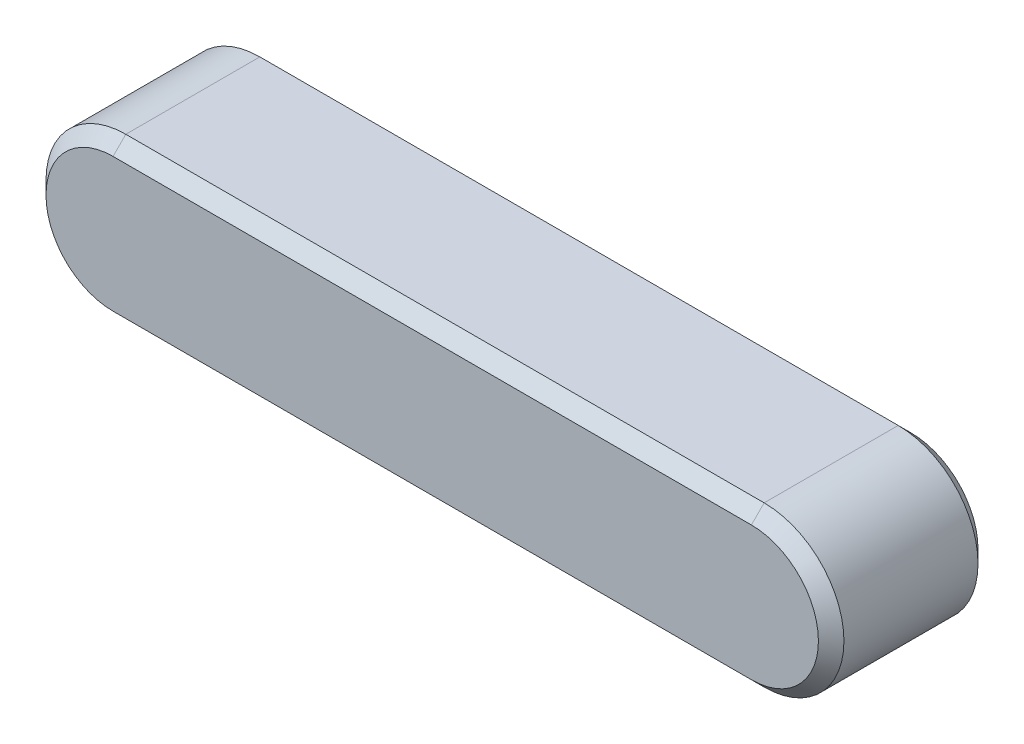
from build123d import *

# Parameters (mm, degrees)
BASEKEY_DEPTH = 2.5
CHAMFER1_SIZE = 0.4


with BuildPart() as part:
    # Sketch1 → BaseKey (new body, symmetric)
    with BuildSketch(Plane.XY):
        with BuildLine():
            Line((-20, 2.5), (0, 2.5))
            ThreePointArc((0, 2.5), (2.5, 0), (0, -2.5))
            Line((0, -2.5), (-20, -2.5))
            ThreePointArc((-20, -2.5), (-22.5, 0), (-20, 2.5))
        make_face()
    extrude(amount=BASEKEY_DEPTH, both=True)

    # Chamfer1
    chamfer1_edges = [part.edges().sort_by_distance(p)[0] for p in [
        (2.5, 0, 2.5),
        (-10, 2.5, 2.5),
        (-22.5, 0, 2.5),
        (-10, 2.5, -2.5),
        (2.5, 0, -2.5),
        (-10, -2.5, -2.5),
        (-22.5, 0, -2.5),
        (-10, -2.5, 2.5),
    ]]
    chamfer(chamfer1_edges, length=CHAMFER1_SIZE)


solid = part.part
